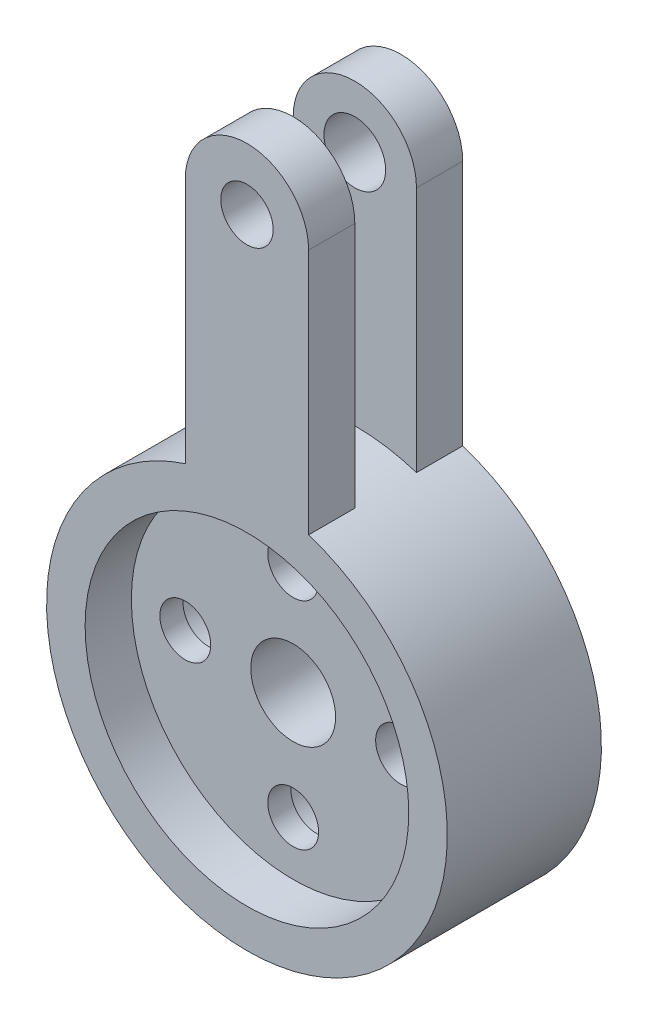
from build123d import *

# Parameters (mm, degrees)
ESQUISSE1_R             = 13
ESQUISSE1_R_2           = 2.75
ESQUISSE1_R_3           = 1.65
BOSS_EXTRU_1_DEPTH      = 10
ESQUISSE2_R             = 10.5
ENL_V_MAT_EXTRU_1_DEPTH = 3
ESQUISSE3_R             = 2.75
ENL_V_MAT_EXTRU_2_DEPTH = 5.5
ESQUISSE4_R             = 1.7
BOSS_EXTRU_2_DEPTH      = 3
ESQUISSE5_R             = 2
ENL_V_MAT_EXTRU_3_DEPTH = 3


with BuildPart() as part:
    # Esquisse1 → Boss.-Extru.1 (new body)
    with BuildSketch(Plane.XY):
        Circle(ESQUISSE1_R)
        Circle(ESQUISSE1_R_2, mode=Mode.SUBTRACT)
        with Locations((-7, 0)):
            Circle(ESQUISSE1_R_3, mode=Mode.SUBTRACT)
        with Locations((0, 7)):
            Circle(ESQUISSE1_R_3, mode=Mode.SUBTRACT)
        with Locations((7, 0)):
            Circle(ESQUISSE1_R_3, mode=Mode.SUBTRACT)
        with Locations((0, -7)):
            Circle(ESQUISSE1_R_3, mode=Mode.SUBTRACT)
    extrude(amount=BOSS_EXTRU_1_DEPTH)

    # Esquisse2 → Enlèv. mat.-Extru.1 (cut)
    with BuildSketch(Plane.XY.offset(10)):
        Circle(ESQUISSE2_R)
    extrude(amount=-ENL_V_MAT_EXTRU_1_DEPTH, mode=Mode.SUBTRACT)

    # Esquisse3 → Enlèv. mat.-Extru.2 (cut)
    with BuildSketch(Plane(origin=(0, 0, 0), x_dir=(-1, 0, 0), z_dir=(0, 0, -1))):
        with Locations((-7, 0)):
            Circle(ESQUISSE3_R)
        with Locations((0, 7)):
            Circle(ESQUISSE3_R)
        with Locations((7, 0)):
            Circle(ESQUISSE3_R)
        with Locations((0, -7)):
            Circle(ESQUISSE3_R)
    extrude(amount=-ENL_V_MAT_EXTRU_2_DEPTH, mode=Mode.SUBTRACT)

    # Esquisse4 → Boss.-Extru.2 (add)
    with BuildSketch(Plane(origin=(0, 0, 0), x_dir=(-1, 0, 0), z_dir=(0, 0, -1))):
        with BuildLine():
            Line((-4, 28.369316877), (-4, 12.369316877))
            ThreePointArc((-4, 12.369316877), (0, 13), (4, 12.369316877))
            Line((4, 12.369316877), (4, 28.369316877))
            ThreePointArc((4, 28.369316877), (0, 32.369316877), (-4, 28.369316877))
        make_face()
        with Locations((0, 28.369316877)):
            Circle(ESQUISSE4_R, mode=Mode.SUBTRACT)
    boss_extru_2 = extrude(amount=-BOSS_EXTRU_2_DEPTH)

    # Symétrie1: Boss.-Extru.2 across plane
    add(boss_extru_2.mirror(Plane.XY.offset(5)))

    # Esquisse5 → Enlèv. mat.-Extru.3 (cut)
    with BuildSketch(Plane(origin=(0, 0, 0), x_dir=(-1, 0, 0), z_dir=(0, 0, -1))):
        with Locations((0, 28.369316877)):
            Circle(ESQUISSE5_R)
    extrude(amount=-ENL_V_MAT_EXTRU_3_DEPTH, mode=Mode.SUBTRACT)


solid = part.part
